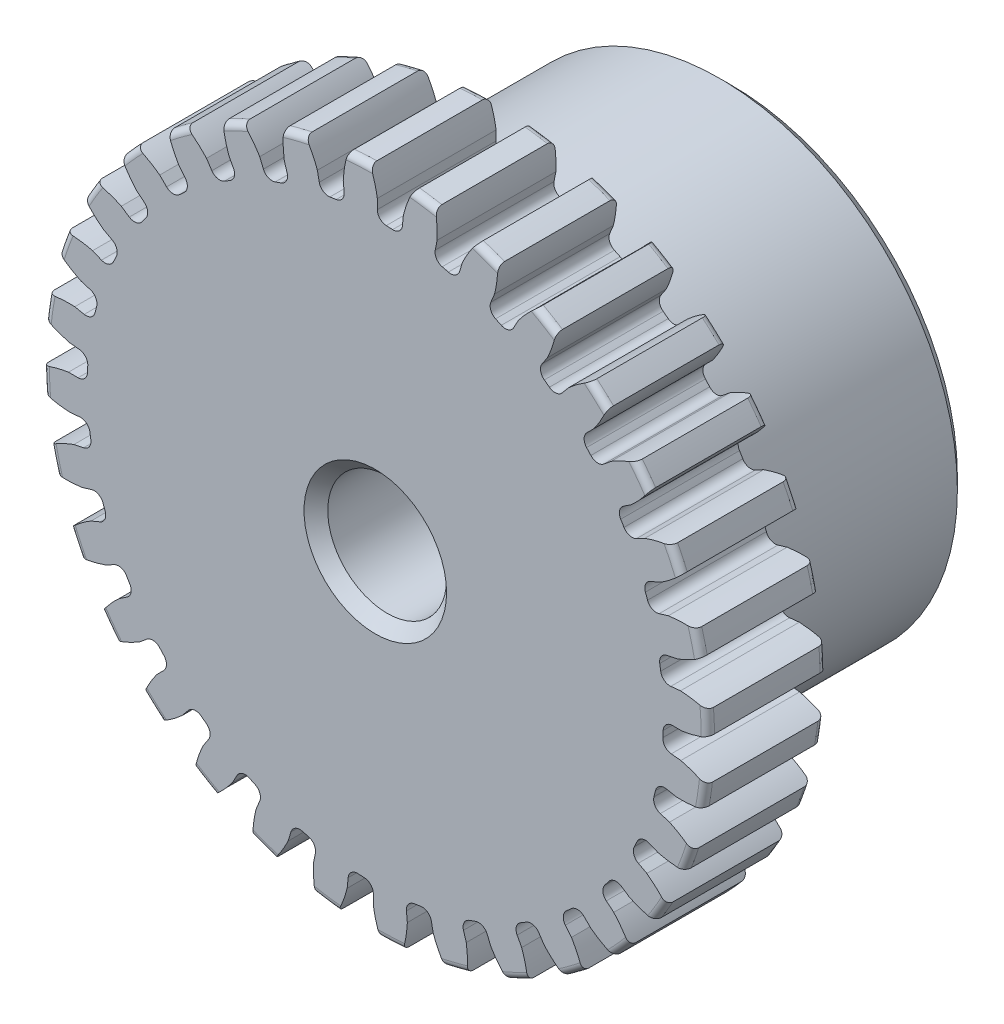
from build123d import *

# Parameters (mm, degrees)
SKETCH1_R                = 8.89
BOSS_EXTRUDE1_DEPTH      = 3.175
SKETCH2_W                = 6.35
SKETCH2_H                = 6.35
FILLET2_R                = 0.1778
CUT_EXTRUDE1_DEPTH       = 10.525
FILLET1_R                = 0.249489182
CIRPATTERN1_COUNT        = 32
FILLET1_OF_CIRPATTERN1_R = 0.249489182
SKETCH5_R                = 1.5875
CUT_EXTRUDE2_DEPTH       = 10.525
CHAMFER1_SIZE            = 0.3175


with BuildPart() as part:
    # Sketch1 → Boss-Extrude1 (new body)
    with BuildSketch(Plane.XY):
        Circle(SKETCH1_R)
    extrude(amount=-BOSS_EXTRUDE1_DEPTH)

    # Sketch2 → Revolve1 (revolve)
    with BuildSketch(Plane(origin=(0, 0, 0), x_dir=(0, 0, -1), z_dir=(1, 0, 0))):
        with Locations((6.35, 3.175)):
            Rectangle(SKETCH2_W, SKETCH2_H)
    revolve(axis=Axis((0, 0, -3.175), (0, 0, -1)))

    # Fillet2
    fillet2_edges = [part.edges().sort_by_distance(p)[0] for p in [
        (-8.89, 0, 0),
        (-8.89, 0, -3.175),
        (0, -6.35, -3.175),
    ]]
    fillet(fillet2_edges, radius=FILLET2_R)

    # Sketch4 → Cut-Extrude1 (cut, through all)
    with BuildSketch(Plane.XY):
        with BuildLine():
            Line((0.053138783, 8.200909689), (0.053138783, 7.698596297))
            ThreePointArc((0.053138783, 7.698596297), (0.377762097, 7.689506127), (0.701713249, 7.666733802))
            Line((0.701713249, 7.666733802), (0.750948686, 8.166628407))
            add(Edge.make_bspline(
                [(1.821754445, 9.820491389), (0.994167126, 9.128663497), (0.750948686, 8.166628407)],
                knots=[0, 0, 0, 1, 1, 1], degree=2))
            ThreePointArc((1.821754445, 9.820491389), (0.490090787, 9.976003779), (-0.850403432, 9.951766395))
            add(Edge.make_bspline(
                [(-0.850403432, 9.951766395), (-0.09461234, 9.182151928), (0.053138783, 8.200909689)],
                knots=[0, 0, 0, 1, 1, 1], degree=2))
        make_face()
    cut_extrude1 = extrude(amount=-CUT_EXTRUDE1_DEPTH, mode=Mode.SUBTRACT)

    # Fillet1
    fillet1_edges = [part.edges().sort_by_distance(p)[0] for p in [
        (0.701713249, 7.666733802, -1.5875),
        (0.053138783, 7.698596297, -1.5875),
    ]]
    fillet(fillet1_edges, radius=FILLET1_R)

    # CirPattern1: Cut-Extrude1 ×32 about axis
    cirpattern1_axis = Axis((0, 0, -3.175), (0, 0, 1))
    for i in range(1, CIRPATTERN1_COUNT):
        add(cut_extrude1.rotate(cirpattern1_axis, i * 360 / CIRPATTERN1_COUNT), mode=Mode.SUBTRACT)

    # Fillet1 of CirPattern1
    fillet1_of_cirpattern1_edges = [part.edges().sort_by_distance(p)[0] for p in [
        (-0.807475541, 7.656317126, -1.5875),
        (-1.449803895, 7.56103679, -1.5875),
        (-2.285633498, 7.351672476, -1.5875),
        (-2.897031422, 7.13291088, -1.5875),
        (-3.675955842, 6.764507175, -1.5875),
        (-4.232927656, 6.430671204, -1.5875),
        (-4.925013265, 5.917385658, -1.5875),
        (-5.406154854, 5.481304441, -1.5875),
        (-5.984805189, 4.842862328, -1.5875),
        (-6.371626553, 4.321294222, -1.5875),
        (-6.814604407, 3.582230515, -1.5875),
        (-7.092240216, 2.995219089, -1.5875),
        (-7.382522198, 2.183935592, -1.5875),
        (-7.540303066, 1.554039367, -1.5875),
        (-7.666733802, 0.701713249, -1.5875),
        (-7.698596297, 0.053138783, -1.5875),
        (-7.656317126, -0.807475541, -1.5875),
        (-7.56103679, -1.449803895, -1.5875),
        (-7.351672476, -2.285633498, -1.5875),
        (-7.13291088, -2.897031422, -1.5875),
        (-6.764507175, -3.675955842, -1.5875),
        (-6.430671204, -4.232927656, -1.5875),
        (-5.917385658, -4.925013265, -1.5875),
        (-5.481304441, -5.406154854, -1.5875),
        (-4.842862328, -5.984805189, -1.5875),
        (-4.321294222, -6.371626553, -1.5875),
        (-3.582230515, -6.814604407, -1.5875),
        (-2.995219089, -7.092240216, -1.5875),
        (-2.183935592, -7.382522198, -1.5875),
        (-1.554039367, -7.540303066, -1.5875),
        (-0.701713249, -7.666733802, -1.5875),
        (-0.053138783, -7.698596297, -1.5875),
        (0.807475541, -7.656317126, -1.5875),
        (1.449803895, -7.56103679, -1.5875),
        (2.285633498, -7.351672476, -1.5875),
        (2.897031422, -7.13291088, -1.5875),
        (3.675955842, -6.764507175, -1.5875),
        (4.232927656, -6.430671204, -1.5875),
        (4.925013265, -5.917385658, -1.5875),
        (5.406154854, -5.481304441, -1.5875),
        (5.984805189, -4.842862328, -1.5875),
        (6.371626553, -4.321294222, -1.5875),
        (6.814604407, -3.582230515, -1.5875),
        (7.092240216, -2.995219089, -1.5875),
        (7.382522198, -2.183935592, -1.5875),
        (7.540303066, -1.554039367, -1.5875),
        (7.666733802, -0.701713249, -1.5875),
        (7.698596297, -0.053138783, -1.5875),
        (7.656317126, 0.807475541, -1.5875),
        (7.56103679, 1.449803895, -1.5875),
        (7.351672476, 2.285633498, -1.5875),
        (7.13291088, 2.897031422, -1.5875),
        (6.764507175, 3.675955842, -1.5875),
        (6.430671204, 4.232927656, -1.5875),
        (5.917385658, 4.925013265, -1.5875),
        (5.481304441, 5.406154854, -1.5875),
        (4.842862328, 5.984805189, -1.5875),
        (4.321294222, 6.371626553, -1.5875),
        (3.582230515, 6.814604407, -1.5875),
        (2.995219089, 7.092240216, -1.5875),
        (2.183935592, 7.382522198, -1.5875),
        (1.554039367, 7.540303066, -1.5875),
    ]]
    fillet(fillet1_of_cirpattern1_edges, radius=FILLET1_OF_CIRPATTERN1_R)

    # Sketch5 → Cut-Extrude2 (cut, through all)
    with BuildSketch(Plane.XY):
        Circle(SKETCH5_R)
    extrude(amount=-CUT_EXTRUDE2_DEPTH, mode=Mode.SUBTRACT)

    # Chamfer1
    chamfer1_edges = [part.edges().sort_by_distance(p)[0] for p in [
        (-1.5875, 0, -9.525),
        (-1.5875, 0, 0),
        (0, -6.35, -9.525),
    ]]
    chamfer(chamfer1_edges, length=CHAMFER1_SIZE)


solid = part.part
